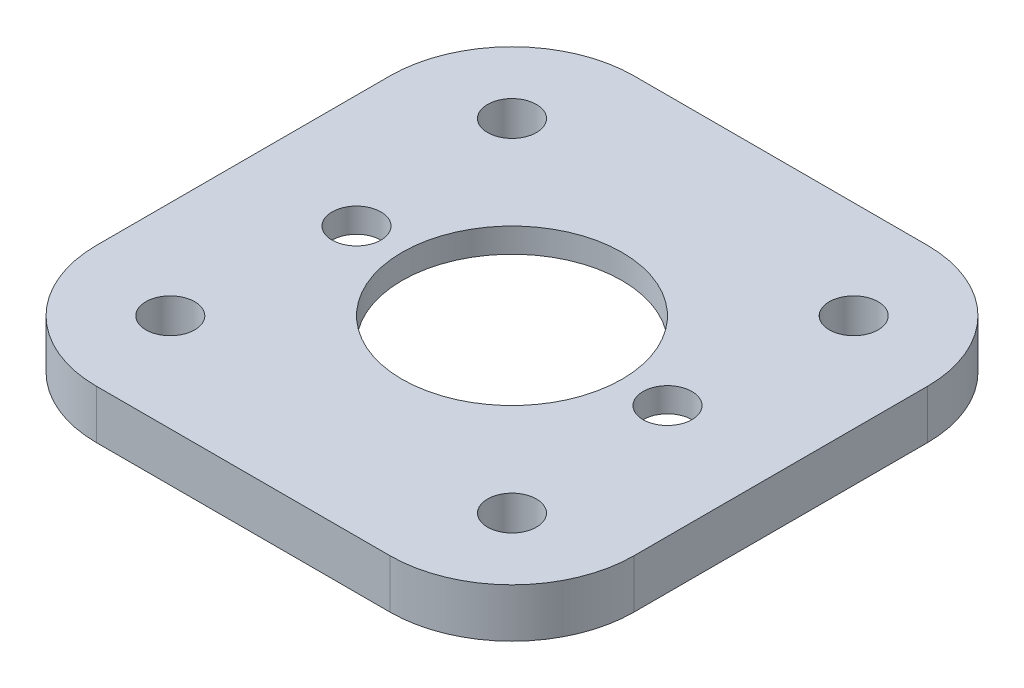
from build123d import *

# Parameters (mm, degrees)
SKETCH1_R           = 1
SKETCH1_R_2         = 4.5
BOSS_EXTRUDE1_DEPTH = 2
SKETCH1_4_R         = 1
SKETCH1_4_R_2       = 4.5
CUT_EXTRUDE1_DEPTH  = 1


with BuildPart() as part:
    # Sketch1 → Boss-Extrude1 (new body)
    with BuildSketch(Plane(origin=(0, 0, 0), x_dir=(1, 0, 0), z_dir=(0, 1, 0))):
        with BuildLine():
            Line((6, 11), (-6, 11))
            ThreePointArc((-6, 11), (-9.535533906, 9.535533906), (-11, 6))
            Line((-11, 6), (-11, -6))
            ThreePointArc((-11, -6), (-9.535533906, -9.535533906), (-6, -11))
            Line((-6, -11), (6, -11))
            ThreePointArc((6, -11), (9.535533906, -9.535533906), (11, -6))
            Line((11, -6), (11, 6))
            ThreePointArc((11, 6), (9.535533906, 9.535533906), (6, 11))
        make_face()
        with Locations((-6.992221877, -6.992221877)):
            Circle(SKETCH1_R, mode=Mode.SUBTRACT)
        with Locations((6.992221877, -6.992221877)):
            Circle(SKETCH1_R, mode=Mode.SUBTRACT)
        with Locations((-6.992221877, 6.992221877)):
            Circle(SKETCH1_R, mode=Mode.SUBTRACT)
        with Locations((6.992221877, 6.992221877)):
            Circle(SKETCH1_R, mode=Mode.SUBTRACT)
        Circle(SKETCH1_R_2, mode=Mode.SUBTRACT)
        with Locations((6.363961031, 0)):
            Circle(SKETCH1_R, mode=Mode.SUBTRACT)
        with Locations((-6.363961031, 0)):
            Circle(SKETCH1_R, mode=Mode.SUBTRACT)
    extrude(amount=BOSS_EXTRUDE1_DEPTH)

    # Sketch1_4 → Cut-Extrude1 (cut)
    with BuildSketch(Plane(origin=(0, 0, 0), x_dir=(1, 0, 0), z_dir=(0, 1, 0))):
        with BuildLine():
            Line((9.192388155, 2.121320344), (2.121320344, 9.192388155))
            ThreePointArc((2.121320344, 9.192388155), (0, 10.071067812), (-2.121320344, 9.192388155))
            Line((-2.121320344, 9.192388155), (-9.192388155, 2.121320344))
            ThreePointArc((-9.192388155, 2.121320344), (-10.071067812, 0), (-9.192388155, -2.121320344))
            Line((-9.192388155, -2.121320344), (-2.121320344, -9.192388155))
            ThreePointArc((-2.121320344, -9.192388155), (0, -10.071067812), (2.121320344, -9.192388155))
            Line((2.121320344, -9.192388155), (9.192388155, -2.121320344))
            ThreePointArc((9.192388155, -2.121320344), (10.071067812, 0), (9.192388155, 2.121320344))
        make_face()
        with Locations((-6.363961031, 0)):
            Circle(SKETCH1_4_R, mode=Mode.SUBTRACT)
        Circle(SKETCH1_4_R_2, mode=Mode.SUBTRACT)
        with Locations((6.363961031, 0)):
            Circle(SKETCH1_4_R, mode=Mode.SUBTRACT)
    extrude(amount=CUT_EXTRUDE1_DEPTH, mode=Mode.SUBTRACT)


solid = part.part
